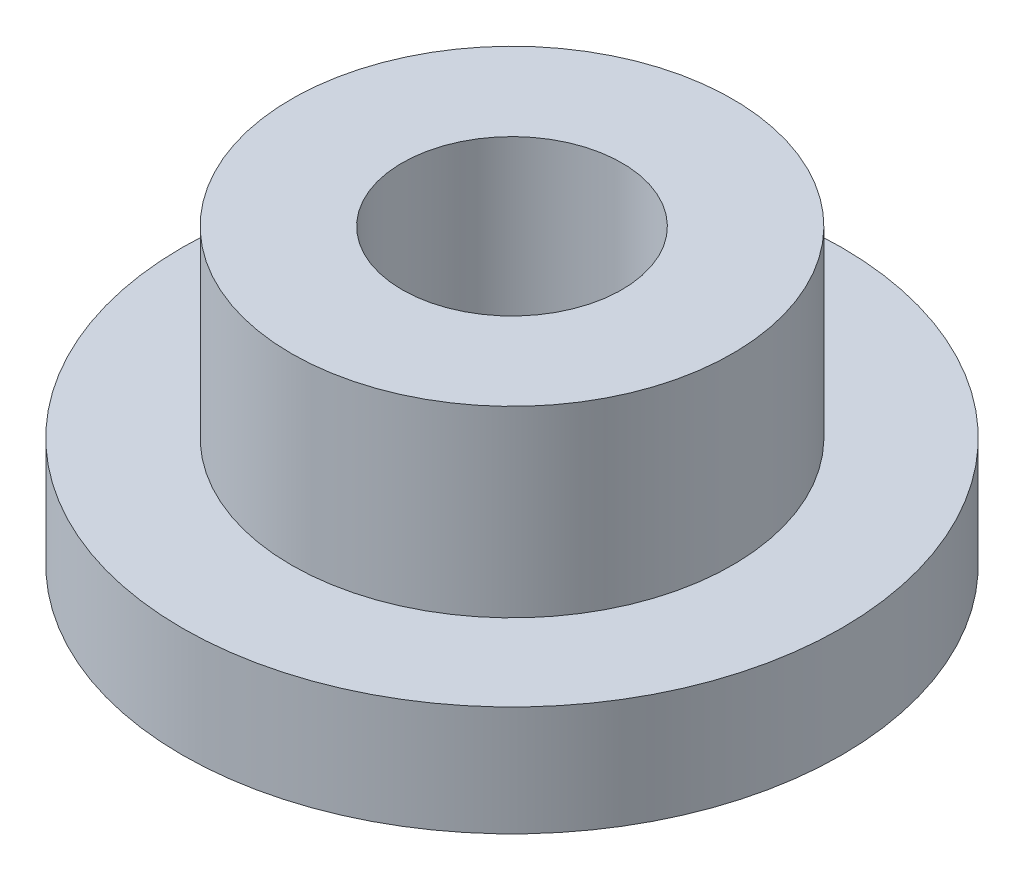
from build123d import *

# Parameters (mm, degrees)
SKETCH2_R           = 3.01
SKETCH2_R_2         = 1.5
BOSS_EXTRUDE1_DEPTH = 4
SKETCH3_R           = 4.5
SKETCH3_R_2         = 3.01
BOSS_EXTRUDE2_DEPTH = 1.5


with BuildPart() as part:
    # Sketch2 → Boss-Extrude1 (new body)
    with BuildSketch(Plane(origin=(0, 0, 0), x_dir=(1, 0, 0), z_dir=(0, 1, 0))):
        Circle(SKETCH2_R)
        Circle(SKETCH2_R_2, mode=Mode.SUBTRACT)
    extrude(amount=BOSS_EXTRUDE1_DEPTH)

    # Sketch3 → Boss-Extrude2 (add)
    with BuildSketch(Plane(origin=(0, 0, 0), x_dir=(1, 0, 0), z_dir=(0, 1, 0))):
        Circle(SKETCH3_R)
        Circle(SKETCH3_R_2, mode=Mode.SUBTRACT)
    extrude(amount=BOSS_EXTRUDE2_DEPTH)


solid = part.part
